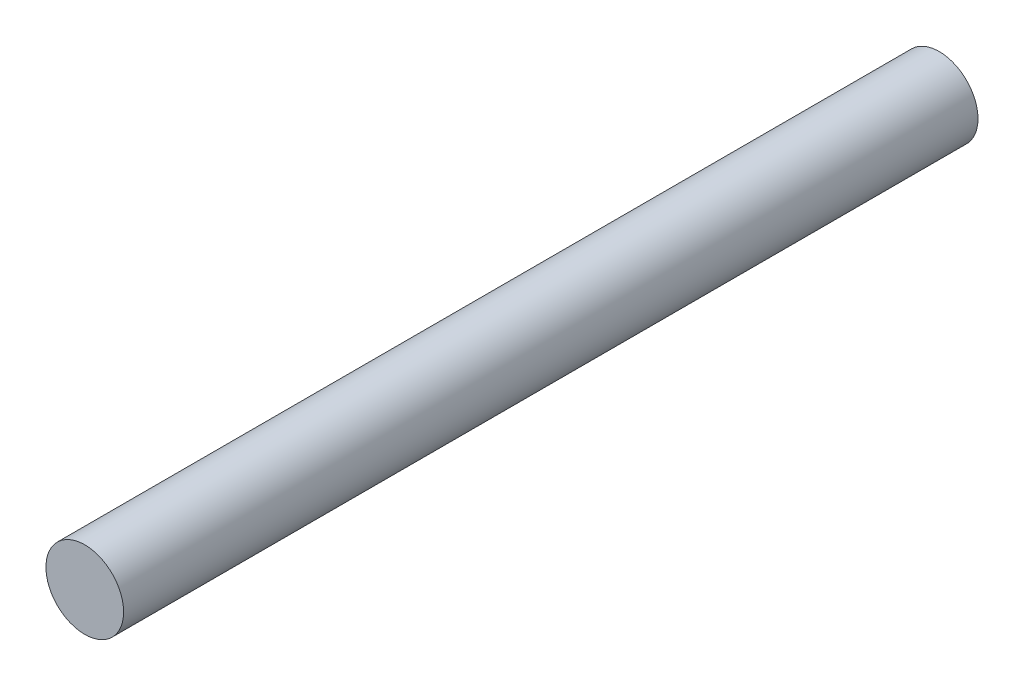
from build123d import *

# Parameters (mm, degrees)
SKETCH1_R           = 2.5
BOSS_EXTRUDE1_DEPTH = 55


with BuildPart() as part:
    # Sketch1 → Boss-Extrude1 (new body)
    with BuildSketch(Plane.XY):
        Circle(SKETCH1_R)
    extrude(amount=-BOSS_EXTRUDE1_DEPTH)


solid = part.part
